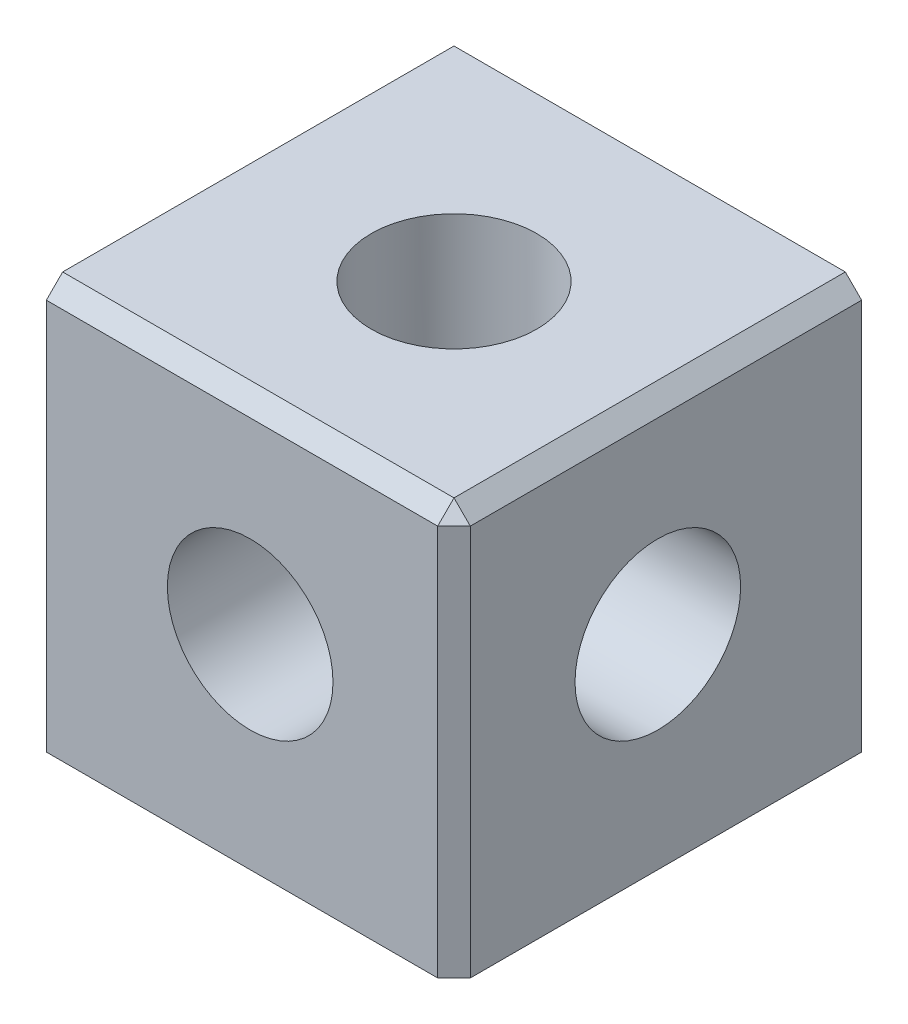
from build123d import *

# Parameters (mm, degrees)
SKETCH1_W           = 25.4
SKETCH1_H           = 25.4
BOSS_EXTRUDE1_DEPTH = 25.4
SKETCH6_W           = 2.96999914
SKETCH6_H           = 6.19999776
BOSS_EXTRUDE2_DEPTH = 2.20999812
BOSS_EXTRUDE3_REACH = 42.371
SKETCH7_W           = 6.19999776
SKETCH7_H           = 2.96999914
SKETCH8_W           = 6.19999776
SKETCH8_H           = 2.96999914
BOSS_EXTRUDE4_DEPTH = 2.20999812
BOSS_EXTRUDE5_REACH = 42.371
SKETCH9_W           = 6.19999776
SKETCH9_H           = 2.96999914
SKETCH10_W          = 2.96999914
SKETCH10_H          = 6.19999776
BOSS_EXTRUDE6_DEPTH = 2.20999812
BOSS_EXTRUDE7_REACH = 42.371
SKETCH11_W          = 2.96999914
SKETCH11_H          = 6.19999776
HOLE3_REACH         = 42.371
HOLE3_BORE_R        = 5.15999984
HOLE4_D             = 6.51999712
HOLE4_CBORE_D       = 10.31999968
HOLE4_CBORE_DEPTH   = 22.09999898
CHAMFER1_SIZE       = 1.016


with BuildPart() as part:
    # Sketch1 → Boss-Extrude1 (new body)
    with BuildSketch(Plane(origin=(0, 25.4, 0), x_dir=(1, 0, 0), z_dir=(0, 1, 0))):
        Rectangle(SKETCH1_W, SKETCH1_H)
    extrude(amount=-BOSS_EXTRUDE1_DEPTH)

    # Sketch2 → Hole1 (revolve, cut)
    with BuildSketch(Plane(origin=(0, 0, 0), x_dir=(0, 0, -1), z_dir=(1, 0, 0))):
        Polygon((0, 0), (0, 25.4), (5.15999984, 25.4), (5.15999984, 3.30000102), (3.25999856, 3.30000102), (3.25999856, 0), align=None)
    revolve(axis=Axis((0, 110, 0), (0, -1, 0)), mode=Mode.SUBTRACT)

    # Sketch4 → Hole2 (revolve, cut)
    with BuildSketch(Plane(origin=(0, 12.7, -12.7), x_dir=(0, 1, 0), z_dir=(1, 0, 0))):
        Polygon((0, 0), (0, 12.7), (5.15999984, 12.7), (5.15999984, 3.30000102), (3.25999856, 3.30000102), (3.25999856, 0), align=None)
    revolve(axis=Axis((0, 12.7, 97.3), (0, 0, -1)), mode=Mode.SUBTRACT)

    # Sketch6 → Boss-Extrude2 (add)
    with BuildSketch(Plane(origin=(0, 0, -12.7), x_dir=(-1, 0, 0), z_dir=(0, 0, -1))):
        with Locations((11.21500043, 12.7)):
            Rectangle(SKETCH6_W, SKETCH6_H)
    extrude(amount=BOSS_EXTRUDE2_DEPTH)

    # Sketch7 → Boss-Extrude3 (add, up to next)
    with BuildSketch(Plane(origin=(-14.90999812, 0, 0), x_dir=(0, -1, 0), z_dir=(-1, 0, 0)), mode=Mode.PRIVATE) as boss_extrude3_sk1:
        with Locations((-12.7, -11.21500043)):
            Rectangle(SKETCH7_W, SKETCH7_H)
    boss_extrude3_tool1 = extrude(boss_extrude3_sk1.sketch, amount=-BOSS_EXTRUDE3_REACH, mode=Mode.PRIVATE) - part.part
    add(boss_extrude3_tool1.solids().sort_by_distance((-14.909998, 12.7, -11.215))[0])

    # Sketch8 → Boss-Extrude4 (add)
    with BuildSketch(Plane.XZ):
        with Locations((0, -11.21500043)):
            Rectangle(SKETCH8_W, SKETCH8_H)
    extrude(amount=BOSS_EXTRUDE4_DEPTH)

    # Sketch9 → Boss-Extrude5 (add, up to next)
    with BuildSketch(Plane(origin=(0, 0, -14.90999812), x_dir=(-1, 0, 0), z_dir=(0, 0, -1)), mode=Mode.PRIVATE) as boss_extrude5_sk1:
        with Locations((0, 1.48499957)):
            Rectangle(SKETCH9_W, SKETCH9_H)
    boss_extrude5_tool1 = extrude(boss_extrude5_sk1.sketch, amount=-BOSS_EXTRUDE5_REACH, mode=Mode.PRIVATE) - part.part
    add(boss_extrude5_tool1.solids().sort_by_distance((0, 1.485, -14.909998))[0])

    # Sketch10 → Boss-Extrude6 (add)
    with BuildSketch(Plane.XZ):
        with Locations((-11.21500043, 0)):
            Rectangle(SKETCH10_W, SKETCH10_H)
    extrude(amount=BOSS_EXTRUDE6_DEPTH)

    # Sketch11 → Boss-Extrude7 (add, up to next)
    with BuildSketch(Plane(origin=(-14.90999812, 0, 0), x_dir=(0, -1, 0), z_dir=(-1, 0, 0)), mode=Mode.PRIVATE) as boss_extrude7_sk1:
        with Locations((-1.48499957, 0)):
            Rectangle(SKETCH11_W, SKETCH11_H)
    boss_extrude7_tool1 = extrude(boss_extrude7_sk1.sketch, amount=-BOSS_EXTRUDE7_REACH, mode=Mode.PRIVATE) - part.part
    add(boss_extrude7_tool1.solids().sort_by_distance((-14.909998, 1.485, 0))[0])

    # Hole3 bore → Hole3 (cut, up to next)
    with BuildSketch(Plane.XY.offset(12.7), mode=Mode.PRIVATE) as hole3_sk1:
        with Locations((0, 12.7)):
            Circle(HOLE3_BORE_R)
    hole3_tool1 = extrude(hole3_sk1.sketch, amount=-HOLE3_REACH, mode=Mode.PRIVATE) & part.part
    add(hole3_tool1.solids().sort_by_distance((0, 12.7, 12.7))[0], mode=Mode.SUBTRACT)

    # Hole4 (through all)
    with Locations(Plane(origin=(12.7, 0, 0), x_dir=(0, 0, -1), z_dir=(1, 0, 0))):
        with Locations((0, 12.7)):
            CounterBoreHole(HOLE4_D / 2, HOLE4_CBORE_D / 2, HOLE4_CBORE_DEPTH)

    # Chamfer1
    chamfer1_edges = [part.edges().sort_by_distance(p)[0] for p in [
        (12.7, 25.4, 0),
        (0, 25.4, 12.7),
        (12.7, 12.7, 12.7),
    ]]
    chamfer(chamfer1_edges, length=CHAMFER1_SIZE)


solid = part.part
